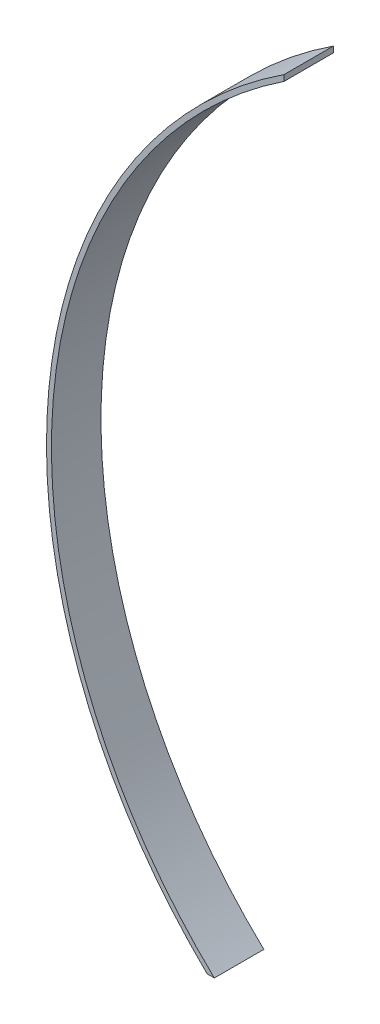
from build123d import *

# Parameters (mm, degrees)
BOSS_EXTRUDE1_DEPTH = 10


with BuildPart() as part:
    # Sketch1 → Boss-Extrude1 (new body)
    with BuildSketch(Plane.XY):
        with BuildLine():
            Line((-10.937324628, 185), (-10.937324628, 186.197519695))
            ThreePointArc((-10.937324628, 186.197519695), (-58.431233219, 107.419527957), (-26.448620268, 21.171305921))
            Line((-26.448620268, 21.171305921), (-25, 21.171305921))
            ThreePointArc((-25, 21.171305921), (-57.511689732, 106.47993478), (-10.937324628, 185))
        make_face()
    extrude(amount=BOSS_EXTRUDE1_DEPTH)


solid = part.part
